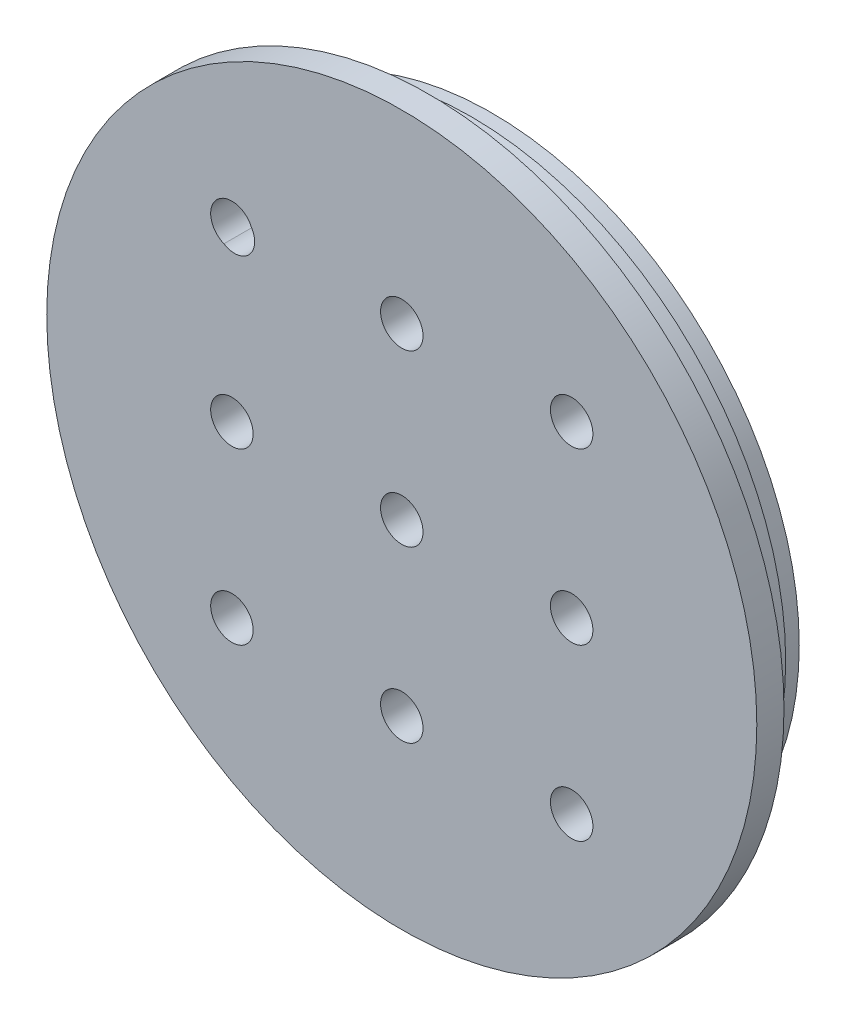
from build123d import *

# Parameters (mm, degrees)
SKETCH2_W                        = 127
SKETCH2_H                        = 127
HOUSING_DEPTH                    = 39.5
SKETCH3_R                        = 19.05
CUT_EXTRUDE1_DEPTH               = 40.5
SKETCH4_OUTSIDE_W                = 165.78
SKETCH4_OUTSIDE_H                = 165.78
SKETCH4_OUTSIDE_R                = 45.974
CUT_EXTRUDE2_DEPTH               = 4.698
MOUNTING_POCKETS_DEPTH           = 24.384
ENG_METRIC_SLOT_VERTICAL_REACH   = 129
ENG_METRIC_SLOT_HORIZONTAL_DEPTH = 40.5
FILLET3_R                        = 0.508
F_10_32_TAPPED_HOLE1_D           = 4.0386
F_10_32_TAPPED_HOLE1_DEPTH       = 12.02944
F_10_32_TAPPED_HOLE1_TIP         = 1.213317848
SKETCH219_R                      = 53.086
EXTRUDE2_DEPTH                   = 10.414
SKETCH222_R                      = 53.086
SKETCH222_R_2                    = 46.99
CUT_EXTRUDE6_DEPTH               = 6.35
LPATTERN14_COUNT                 = 3
LPATTERN14_PITCH                 = 25.4
LPATTERN14_COUNT_DIR2            = 3
LPATTERN14_PITCH_DIR2            = 25.4
M6X1_0_TAPPED_HOLE1_D            = 5
M6X1_0_TAPPED_HOLE1_DEPTH        = 8
M6X1_0_TAPPED_HOLE1_CBORE_D      = 6
M6X1_0_TAPPED_HOLE1_CBORE_DEPTH  = 6
M6X1_0_TAPPED_HOLE1_TIP          = 1.502151548
SKETCH234_W                      = 34.802
SKETCH234_H                      = 127
CUT_EXTRUDE8_DEPTH               = 128


with BuildPart() as part:
    # Sketch2 → HOUSING (new body)
    with BuildSketch(Plane.XY):
        Rectangle(SKETCH2_W, SKETCH2_H)
    extrude(amount=HOUSING_DEPTH)

    # Sketch3 → Cut-Extrude1 (cut, through all)
    with BuildSketch(Plane.XY.offset(39.5)):
        Circle(SKETCH3_R)
    extrude(amount=-CUT_EXTRUDE1_DEPTH, mode=Mode.SUBTRACT)

    # Sketch4 outside → Cut-Extrude2 (cut)
    with BuildSketch(Plane.XY.offset(39.5)):
        Rectangle(SKETCH4_OUTSIDE_W, SKETCH4_OUTSIDE_H)
        Circle(SKETCH4_OUTSIDE_R, mode=Mode.SUBTRACT)
    extrude(amount=-CUT_EXTRUDE2_DEPTH, mode=Mode.SUBTRACT)

    # Sketch8 → MOUNTING POCKETS (cut)
    with BuildSketch(Plane.XY.offset(34.802)):
        with BuildLine():
            Line((3.048, -63.5), (3.048, -57.528018122))
            ThreePointArc((3.048, -57.528018122), (4.194729662, -53.888172274), (7.220748912, -51.562946647))
            Line((7.220748912, -51.562946647), (45.320748912, -37.656446647))
            ThreePointArc((45.320748912, -37.656446647), (51.137845848, -38.418247784), (53.848, -43.621518122))
            Line((53.848, -43.621518122), (53.848, -63.5))
            Line((53.848, -63.5), (3.048, -63.5))
        make_face()
        with BuildLine():
            Line((3.048, 63.5), (53.848, 63.5))
            Line((53.848, 63.5), (53.848, 43.621518122))
            ThreePointArc((53.848, 43.621518122), (51.137845848, 38.418247784), (45.320748912, 37.656446647))
            Line((45.320748912, 37.656446647), (7.220748912, 51.562946647))
            ThreePointArc((7.220748912, 51.562946647), (4.194729662, 53.888172274), (3.048, 57.528018122))
            Line((3.048, 57.528018122), (3.048, 63.5))
        make_face()
    extrude(amount=-MOUNTING_POCKETS_DEPTH, mode=Mode.SUBTRACT)

    # Sketch21 → ENG_METRIC SLOT VERTICAL (cut, up to next)
    with BuildSketch(Plane(origin=(63.5, -23.646142673, 1.166551585), x_dir=(0, 0, -1), z_dir=(1, 0, 0)), mode=Mode.PRIVATE) as eng_metric_slot_vertical_sk1:
        with BuildLine():
            Line((-20.641506099, 75.242113831), (-21.041506099, 76.042113831))
            ThreePointArc((-21.041506099, 76.042113831), (-25.829419573, 77.63808499), (-27.425390732, 72.850171515))
            Line((-27.425390732, 72.850171515), (-27.025390732, 72.050171515))
            ThreePointArc((-27.025390732, 72.050171515), (-22.237477257, 70.454200357), (-20.641506099, 75.242113831))
        make_face()
    eng_metric_slot_vertical_tool1 = extrude(eng_metric_slot_vertical_sk1.sketch, amount=-ENG_METRIC_SLOT_VERTICAL_REACH, mode=Mode.PRIVATE) & part.part
    add(eng_metric_slot_vertical_tool1.solids().sort_by_distance((63.5, 50.4, 25.2))[0], mode=Mode.SUBTRACT)
    # Sketch21 → ENG_METRIC SLOT VERTICAL (cut, up to next)
    with BuildSketch(Plane(origin=(63.5, -23.646142673, 1.166551585), x_dir=(0, 0, -1), z_dir=(1, 0, 0)), mode=Mode.PRIVATE) as eng_metric_slot_vertical_sk2:
        with BuildLine():
            Line((-27.025390732, -24.757886169), (-27.425390732, -25.557886169))
            ThreePointArc((-27.425390732, -25.557886169), (-25.829419573, -30.345799643), (-21.041506099, -28.749828485))
            Line((-21.041506099, -28.749828485), (-20.641506099, -27.949828485))
            ThreePointArc((-20.641506099, -27.949828485), (-22.237477257, -23.16191501), (-27.025390732, -24.757886169))
        make_face()
    eng_metric_slot_vertical_tool2 = extrude(eng_metric_slot_vertical_sk2.sketch, amount=-ENG_METRIC_SLOT_VERTICAL_REACH, mode=Mode.PRIVATE) & part.part
    add(eng_metric_slot_vertical_tool2.solids().sort_by_distance((63.5, -50.4, 25.2))[0], mode=Mode.SUBTRACT)

    # Sketch212 → ENG_METRIC SLOT HORIZONTAL (cut, through all)
    with BuildSketch(Plane(origin=(34.062086582, -104.655987826, 0), x_dir=(-1, 0, 0), z_dir=(0, 0, -1))):
        with BuildLine():
            Line((12.254028899, 156.251958985), (11.854028899, 157.051958985))
            ThreePointArc((11.854028899, 157.051958985), (7.066115424, 158.647930143), (5.470144266, 153.860016668))
            Line((5.470144266, 153.860016668), (5.870144266, 153.060016668))
            ThreePointArc((5.870144266, 153.060016668), (10.658057741, 151.46404551), (12.254028899, 156.251958985))
        make_face()
        with BuildLine():
            Line((5.870144266, 56.251958985), (5.470144266, 55.451958985))
            ThreePointArc((5.470144266, 55.451958985), (7.066115424, 50.66404551), (11.854028899, 52.260016668))
            Line((11.854028899, 52.260016668), (12.254028899, 53.060016668))
            ThreePointArc((12.254028899, 53.060016668), (10.658057741, 57.847930143), (5.870144266, 56.251958985))
        make_face()
    extrude(amount=-ENG_METRIC_SLOT_HORIZONTAL_DEPTH, mode=Mode.SUBTRACT)

    # Fillet3
    fillet3_edges = [part.edges().sort_by_distance(p)[0] for p in [
        (3.048, -60.514009061, 10.418),
        (4.194729662, -53.888172274, 10.418),
        (26.270748912, -44.609696647, 10.418),
        (51.137845848, -38.418247784, 10.418),
        (53.848, -53.560759061, 10.418),
        (51.137845848, 38.418247784, 10.418),
        (26.270748912, 44.609696647, 10.418),
        (4.194729662, 53.888172274, 10.418),
        (3.048, 60.514009061, 10.418),
        (53.848, 53.560759061, 10.418),
    ]]
    fillet(fillet3_edges, radius=FILLET3_R)

    # #10-32 Tapped Hole1
    with Locations(Plane.XY.offset(39.5)):
        with Locations((26.9875, -26.9875), (26.9875, 26.9875), (-26.9875, 26.9875), (-26.9875, -26.9875)):
            Hole(F_10_32_TAPPED_HOLE1_D / 2, depth=F_10_32_TAPPED_HOLE1_DEPTH)
            with Locations((0, 0, -(F_10_32_TAPPED_HOLE1_DEPTH + F_10_32_TAPPED_HOLE1_TIP / 2))):  # 118° drill point
                Cone(0, F_10_32_TAPPED_HOLE1_D / 2, F_10_32_TAPPED_HOLE1_TIP, mode=Mode.SUBTRACT)

    # Sketch219 → Extrude2 (add)
    with BuildSketch(Plane.XY.offset(48.26)):
        Circle(SKETCH219_R)
    extrude(amount=-EXTRUDE2_DEPTH)

    # Sketch222 → Cut-Extrude6 (cut)
    with BuildSketch(Plane(origin=(0, 0, 37.846), x_dir=(-1, 0, 0), z_dir=(0, 0, -1))):
        Circle(SKETCH222_R)
        Circle(SKETCH222_R_2, mode=Mode.SUBTRACT)
    extrude(amount=-CUT_EXTRUDE6_DEPTH, mode=Mode.SUBTRACT)

    # Sketch230 → 1/4-20 Tapped Hole2 (revolve, cut)
    with BuildSketch(Plane(origin=(-25.4, 25.4, 48.26), x_dir=(0, -1, 0), z_dir=(1, 0, 0))):
        Polygon((0, 0), (0, 9.533816902), (2.5527, 8), (2.5527, 6), (3.175, 6), (3.175, 0), align=None)
    f_1_4_20_tapped_hole2 = revolve(axis=Axis((-25.4, 25.4, 54.61), (0, 0, -1)), mode=Mode.SUBTRACT)

    # LPattern14: 1_4-20 Tapped Hole2 3 × 3
    with Locations(*[(i * LPATTERN14_PITCH, -j * LPATTERN14_PITCH_DIR2, 0) for i in range(LPATTERN14_COUNT) for j in range(LPATTERN14_COUNT_DIR2) if (i, j) != (0, 0)]):
        add(f_1_4_20_tapped_hole2, mode=Mode.SUBTRACT)

    # M6x1.0 Tapped Hole1
    with Locations(Plane.XY.offset(48.26)):
        with Locations((-25, 25)):
            CounterBoreHole(M6X1_0_TAPPED_HOLE1_D / 2, M6X1_0_TAPPED_HOLE1_CBORE_D / 2, M6X1_0_TAPPED_HOLE1_CBORE_DEPTH, depth=M6X1_0_TAPPED_HOLE1_DEPTH)
            with Locations((0, 0, -(M6X1_0_TAPPED_HOLE1_DEPTH + M6X1_0_TAPPED_HOLE1_TIP / 2))):  # 118° drill point
                Cone(0, M6X1_0_TAPPED_HOLE1_D / 2, M6X1_0_TAPPED_HOLE1_TIP, mode=Mode.SUBTRACT)

    # Sketch234 → Cut-Extrude8 (cut, through all)
    with BuildSketch(Plane.ZY.offset(63.5)):
        with Locations((17.401, 0)):
            Rectangle(SKETCH234_W, SKETCH234_H)
    extrude(amount=-CUT_EXTRUDE8_DEPTH, mode=Mode.SUBTRACT)


solid = part.part
